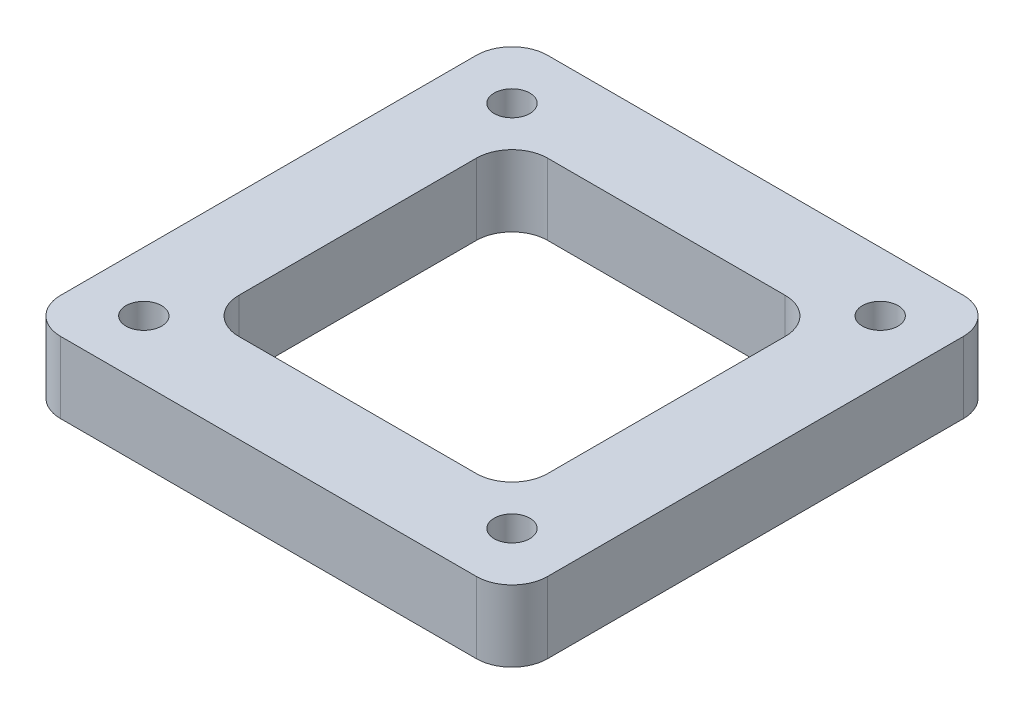
from build123d import *

# Parameters (mm, degrees)
SKETCH1_W           = 41
SKETCH1_H           = 41
BOSS_EXTRUDE1_DEPTH = 6
SKETCH2_R           = 1.5
CUT_EXTRUDE1_DEPTH  = 6
SKETCH3_W           = 26
SKETCH3_H           = 26
CUT_EXTRUDE2_DEPTH  = 6
FILLET1_R           = 3


with BuildPart() as part:
    # Sketch1 → Boss-Extrude1 (new body)
    with BuildSketch(Plane(origin=(0, 0, 0), x_dir=(1, 0, 0), z_dir=(0, 1, 0))):
        Rectangle(SKETCH1_W, SKETCH1_H)
    extrude(amount=BOSS_EXTRUDE1_DEPTH)

    # Sketch2 → Cut-Extrude1 (cut)
    with BuildSketch(Plane(origin=(0, 0, 0), x_dir=(1, 0, 0), z_dir=(0, 1, 0))):
        with Locations((-15.5, 15.5)):
            Circle(SKETCH2_R)
        with Locations((15.5, 15.5)):
            Circle(SKETCH2_R)
        with Locations((-15.5, -15.5)):
            Circle(SKETCH2_R)
        with Locations((15.5, -15.5)):
            Circle(SKETCH2_R)
    extrude(amount=CUT_EXTRUDE1_DEPTH, mode=Mode.SUBTRACT)

    # Sketch3 → Cut-Extrude2 (cut)
    with BuildSketch(Plane(origin=(0, 0, 0), x_dir=(1, 0, 0), z_dir=(0, 1, 0))):
        Rectangle(SKETCH3_W, SKETCH3_H)
    extrude(amount=CUT_EXTRUDE2_DEPTH, mode=Mode.SUBTRACT)

    # Fillet1
    fillet1_edges = [part.edges().sort_by_distance(p)[0] for p in [
        (13, 3, 13),
        (13, 3, -13),
        (-13, 3, -13),
        (-13, 3, 13),
        (20.5, 3, 20.5),
        (-20.5, 3, 20.5),
        (-20.5, 3, -20.5),
        (20.5, 3, -20.5),
    ]]
    fillet(fillet1_edges, radius=FILLET1_R)


solid = part.part
